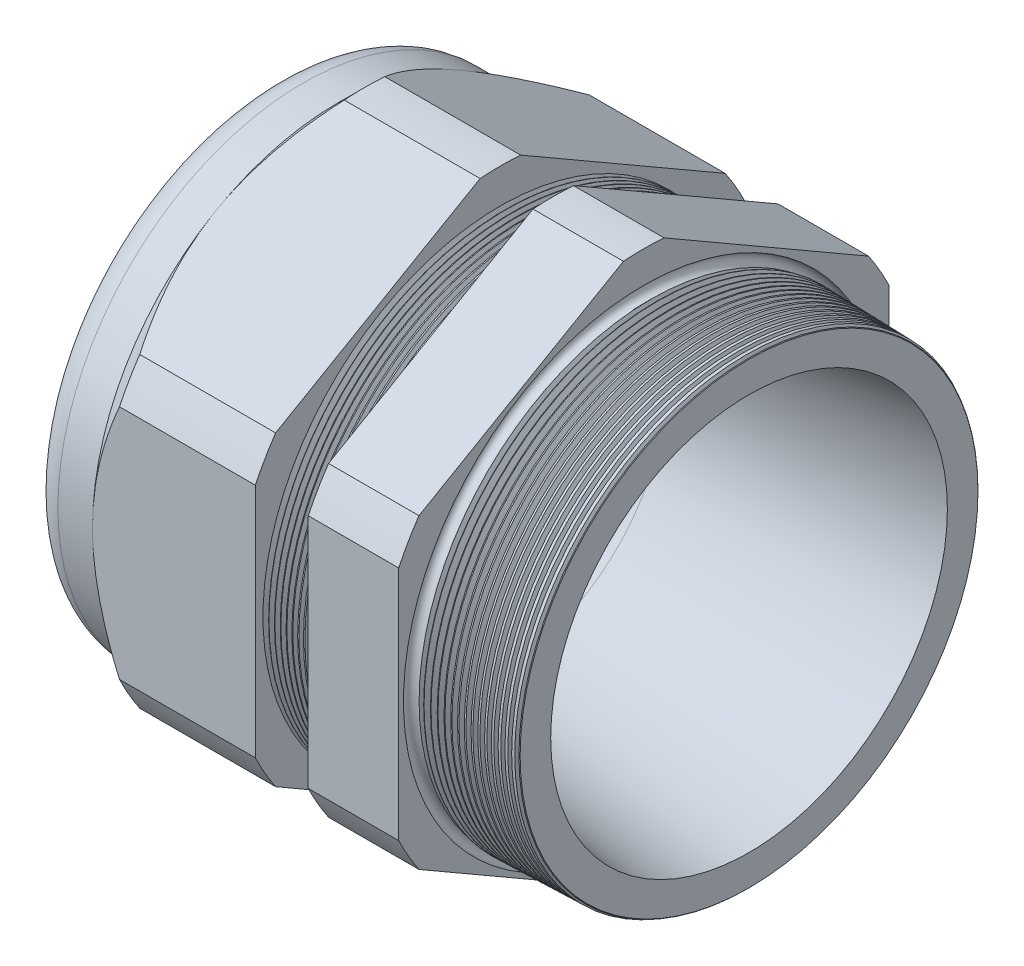
from build123d import *

# Parameters (mm, degrees)
SKETCH12_OUTSIDE_W = 170.928
SKETCH12_OUTSIDE_H = 170.928
CUT_EXTRUDE2_DEPTH = 55.5920168
FILLET4_R          = 3.81
SKETCH19_OUTSIDE_W = 98.176
SKETCH19_OUTSIDE_H = 105.328
SKETCH19_OUTSIDE_R = 32.512
CUT_EXTRUDE3_DEPTH = 3.99796
CUT_EXTRUDE3_DRAFT = -45
CHAMFER1_SIZE      = 0.260919487
CHAMFER1_SIZE2     = 0.254
SKETCH21_R         = 21.971
PLUG_DEPTH         = 12.7
SKETCH22_R         = 21.717
CUT_EXTRUDE4_DEPTH = 0.508
SKETCH27_R         = 4.953
PLUGHOLES_DEPTH    = 63.484
CIRPATTERN1_COUNT  = 8
LPATTERN1_COUNT    = 9
LPATTERN1_PITCH    = 0.762
LPATTERN2_COUNT    = 16
LPATTERN2_PITCH    = 0.889
SKETCH32_R         = 0.889


with BuildPart() as part:
    # Sketch10 → Revolve2 (revolve)
    with BuildSketch(Plane.XY, mode=Mode.PRIVATE) as revolve2_sk:
        Polygon((-56.896, 21.971), (-26.89359112, 21.971), (6.096, 26.314137154), (6.096, 30.632137154), (-7.874, 30.997954479), (-7.874, 65.024), (-19.873976, 65.024), (-19.873976, 31.312184909), (-26.89359112, 31.496), (-26.89359112, 65.024), (-48.4960168, 65.024), (-48.4960168, 32.512), (-56.896, 32.512), align=None)
    revolve(revolve2_sk.sketch.rotate(Axis((0, 0, 0), (-1, 0, 0)), 90), axis=Axis((0, 0, 0), (-1, 0, 0)))  # turned: the seam where the file's is

    # Sketch12 outside → Cut-Extrude2 (cut, through all)
    with BuildSketch(Plane.ZY.offset(48.4960168)):
        Rectangle(SKETCH12_OUTSIDE_W, SKETCH12_OUTSIDE_H)
        with BuildLine():
            Line((-2.69124706, 35.987831689), (-29.82075294, 20.324604167))
            ThreePointArc((-29.82075294, 20.324604167), (-31.2534019, 18.04416), (-32.512, 15.663227523))
            Line((-32.512, 15.663227523), (-32.512, -15.663227523))
            ThreePointArc((-32.512, -15.663227523), (-31.2534019, -18.04416), (-29.82075294, -20.324604167))
            Line((-29.82075294, -20.324604167), (-2.69124706, -35.987831689))
            ThreePointArc((-2.69124706, -35.987831689), (0, -36.08832), (2.69124706, -35.987831689))
            Line((2.69124706, -35.987831689), (29.82075294, -20.324604167))
            ThreePointArc((29.82075294, -20.324604167), (31.2534019, -18.04416), (32.512, -15.663227523))
            Line((32.512, -15.663227523), (32.512, 15.663227523))
            ThreePointArc((32.512, 15.663227523), (31.2534019, 18.04416), (29.82075294, 20.324604167))
            Line((29.82075294, 20.324604167), (2.69124706, 35.987831689))
            ThreePointArc((2.69124706, 35.987831689), (0, 36.08832), (-2.69124706, 35.987831689))
        make_face(mode=Mode.SUBTRACT)
    extrude(amount=-CUT_EXTRUDE2_DEPTH, mode=Mode.SUBTRACT)

    # Fillet4
    fillet4_edges = [part.edges().sort_by_distance(p)[0] for p in [
        (-56.896, 0, 32.512),
    ]]
    fillet(fillet4_edges, radius=FILLET4_R)


with BuildPart() as cut_extrude3_tool:
    # Sketch19 outside → Cut-Extrude3 (with draft: the straight prism first)
    with BuildSketch(Plane.ZY.offset(48.4960168)):
        Rectangle(SKETCH19_OUTSIDE_W, SKETCH19_OUTSIDE_H)
        Circle(SKETCH19_OUTSIDE_R, mode=Mode.SUBTRACT)
    extrude(amount=-CUT_EXTRUDE3_DEPTH)
    # Cut-Extrude3: the draft: its side faces are tilted about the plane it starts from
    cut_extrude3_sides = [cut_extrude3_tool.faces().sort_by_distance(p)[0] for p in [
        (-46.4970368, -52.664, 0),
        (-46.4970368, 0, 49.088),
        (-46.4970368, 52.664, 0),
        (-46.4970368, 0, -49.088),
        (-46.4970368, 0, -32.512),
    ]]
    draft(cut_extrude3_sides, Plane.ZY.offset(48.4960168), CUT_EXTRUDE3_DRAFT)


with BuildPart() as part_1:
    add(part.part)

    # Cut-Extrude3: cut by cut_extrude3_tool
    add(cut_extrude3_tool.part, mode=Mode.SUBTRACT)

    # Chamfer1
    chamfer1_edges = [part_1.edges().sort_by_distance(p)[0] for p in [
        (6.096, 0, 30.632137154),
    ]]
    chamfer1_side = [part_1.faces().sort_by_distance(p)[0] for p in [
        (6.096, 0, 27.18054483),
    ]]
    chamfer(chamfer1_edges, length=CHAMFER1_SIZE, length2=CHAMFER1_SIZE2, reference=chamfer1_side[0])

    # Sketch29 → Cut-Revolve1 (revolve, cut)
    with BuildSketch(Plane.XY, mode=Mode.PRIVATE) as cut_revolve1_sk:
        Polygon((-26.89359112, 31.496), (-26.160607539, 31.476806149), (-26.543721692, 30.851620673), align=None)
    cut_revolve1 = revolve(cut_revolve1_sk.sketch.rotate(Axis((0, 0, 0), (-1, 0, 0)), 90), axis=Axis((0, 0, 0), (-1, 0, 0)), mode=Mode.SUBTRACT)  # turned: the seam where the file's is

    # LPattern1: Cut-Revolve1 ×9
    with Locations(*[(i * LPATTERN1_PITCH, 0, 0) for i in range(1, LPATTERN1_COUNT)]):
        add(cut_revolve1, mode=Mode.SUBTRACT)

    # Sketch30 → Cut-Revolve2 (revolve, cut)
    with BuildSketch(Plane.XY, mode=Mode.PRIVATE) as cut_revolve2_sk:
        Polygon((-7.874, 30.997954479), (-6.994419703, 30.974921858), (-7.454156686, 30.224699287), align=None)
    cut_revolve2 = revolve(cut_revolve2_sk.sketch.rotate(Axis((0, 0, 0), (-1, 0, 0)), 270), axis=Axis((0, 0, 0), (-1, 0, 0)), mode=Mode.SUBTRACT)  # turned: the seam where the file's is

    # LPattern2: Cut-Revolve2 ×16
    with Locations(*[(i * LPATTERN2_PITCH, 0, 0) for i in range(1, LPATTERN2_COUNT)]):
        add(cut_revolve2, mode=Mode.SUBTRACT)

    # Sketch32 → Cut-Revolve3 (revolve, cut)
    with BuildSketch(Plane.XY, mode=Mode.PRIVATE) as cut_revolve3_sk:
        with Locations((-7.747, 30.997954479)):
            Circle(SKETCH32_R)
    revolve(cut_revolve3_sk.sketch.rotate(Axis((0, 0, 0), (-1, 0, 0)), 270), axis=Axis((0, 0, 0), (-1, 0, 0)), mode=Mode.SUBTRACT)  # turned: the seam where the file's is


with BuildPart() as body_2:
    # Sketch21 → plug (new body)
    with BuildSketch(Plane.ZY.offset(56.896)):
        Circle(SKETCH21_R)
    extrude(amount=-PLUG_DEPTH)

    # Sketch22 → Cut-Extrude4 (cut)
    with BuildSketch(Plane.ZY.offset(56.896)):
        Circle(SKETCH22_R)
    extrude(amount=-CUT_EXTRUDE4_DEPTH, mode=Mode.SUBTRACT)

    # Sketch27 → plugholes (cut, through all)
    with BuildSketch(Plane.ZY.offset(56.388)):
        with Locations((-16.744188, 0)):
            Circle(SKETCH27_R)
    plugholes = extrude(amount=-PLUGHOLES_DEPTH, mode=Mode.SUBTRACT)

    # CirPattern1: plugholes ×8 about axis
    cirpattern1_axis = Axis((0, 0, 0), (1, 0, 0))
    for i in range(1, CIRPATTERN1_COUNT):
        add(plugholes.rotate(cirpattern1_axis, i * 360 / CIRPATTERN1_COUNT), mode=Mode.SUBTRACT)


solid = Compound([part_1.part, body_2.part])
